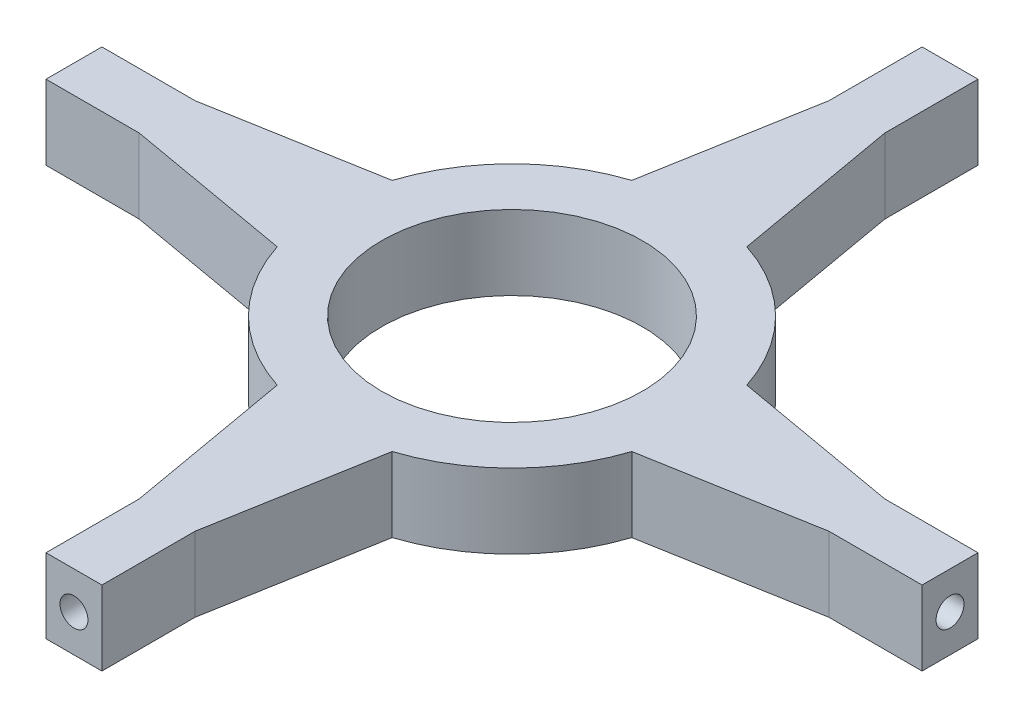
from build123d import *

# Parameters (mm, degrees)
SKETCH1_R           = 70
BOSS_EXTRUDE1_DEPTH = 40
SKETCH2_R           = 7.5
CUT_EXTRUDE1_DEPTH  = 30
CIRPATTERN1_COUNT   = 4


with BuildPart() as part:
    # Sketch1 → Boss-Extrude1 (new body)
    with BuildSketch(Plane(origin=(0, 0, 0), x_dir=(1, 0, 0), z_dir=(0, 1, 0))):
        with BuildLine():
            Line((95.123177318, 30.847708779), (185, 15))
            Line((185, 15), (235, 15))
            Line((235, 15), (235, -15))
            Line((235, -15), (185, -15))
            Line((185, -15), (95.123177318, -30.847708779))
            ThreePointArc((95.123177318, -30.847708779), (70.710678119, -70.710678119), (30.847708779, -95.123177318))
            Line((30.847708779, -95.123177318), (15, -185))
            Line((15, -185), (15, -235))
            Line((15, -235), (-15, -235))
            Line((-15, -235), (-15, -185))
            Line((-15, -185), (-30.847708779, -95.123177318))
            ThreePointArc((-30.847708779, -95.123177318), (-70.710678119, -70.710678119), (-95.123177318, -30.847708779))
            Line((-95.123177318, -30.847708779), (-185, -15))
            Line((-185, -15), (-235, -15))
            Line((-235, -15), (-235, 15))
            Line((-235, 15), (-185, 15))
            Line((-185, 15), (-95.123177318, 30.847708779))
            ThreePointArc((-95.123177318, 30.847708779), (-70.710678119, 70.710678119), (-30.847708779, 95.123177318))
            Line((-30.847708779, 95.123177318), (-15, 185))
            Line((-15, 185), (-15, 235))
            Line((-15, 235), (15, 235))
            Line((15, 235), (15, 185))
            Line((15, 185), (30.847708779, 95.123177318))
            ThreePointArc((30.847708779, 95.123177318), (70.710678119, 70.710678119), (95.123177318, 30.847708779))
        make_face()
        Circle(SKETCH1_R, mode=Mode.SUBTRACT)
    extrude(amount=BOSS_EXTRUDE1_DEPTH)

    # Sketch2 → Cut-Extrude1 (cut)
    with BuildSketch(Plane.XY.offset(235)):
        with Locations((0, 20)):
            Circle(SKETCH2_R)
    cut_extrude1 = extrude(amount=-CUT_EXTRUDE1_DEPTH, mode=Mode.SUBTRACT)

    # CirPattern1: Cut-Extrude1 ×4 about axis
    cirpattern1_axis = Axis((0, 0, 0), (0, 1, 0))
    for i in range(1, CIRPATTERN1_COUNT):
        add(cut_extrude1.rotate(cirpattern1_axis, i * 360 / CIRPATTERN1_COUNT), mode=Mode.SUBTRACT)


solid = part.part
